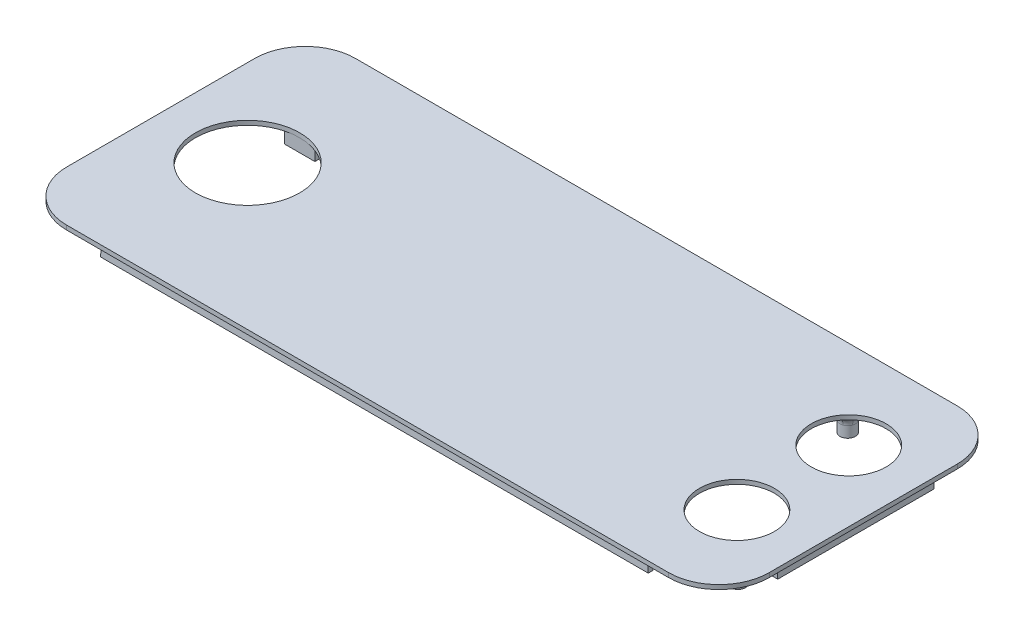
from build123d import *

# Parameters (mm, degrees)
BOSS_EXTRUDE1_DEPTH  = 1
HOLES_R              = 8.625
HOLES_R_2            = 12
CUT_EXTRUDE2_DEPTH   = 1
SKETCH2_W            = 7
SKETCH2_H            = 4.75
BOSS_EXTRUDE2_DEPTH  = 3
SKETCH3_R            = 1
CUT_EXTRUDE3_DEPTH   = 2.5
BOARD_POST_HOLES_R   = 1.75
BOARD_POST_HOLES_R_2 = 1
BOSS_EXTRUDE3_DEPTH  = 5
END_STOPS_W          = 1.8
END_STOPS_H          = 36
BOSS_EXTRUDE4_DEPTH  = 3
SKETCH7_W            = 125.842369002
SKETCH7_H            = 0.8
SKETCH7_W_2          = 127.094788144
BOSS_EXTRUDE5_DEPTH  = 3
BOSS_EXTRUDE5_TAPER  = -3
FILLET1_R            = 2
SKETCH8_R            = 1.75
BOSS_EXTRUDE6_DEPTH  = 5
SKETCH9_R            = 0.55
CUT_EXTRUDE4_DEPTH   = 4
FILLET2_R            = 2.5


with BuildPart() as part:
    # Cover → Boss-Extrude1 (new body)
    with BuildSketch(Plane(origin=(0, 0, 0), x_dir=(1, 0, 0), z_dir=(0, 1, 0))):
        with BuildLine():
            Line((85.9, -21.65), (85.9, 21.65))
            ThreePointArc((85.9, 21.65), (82.502438662, 29.852438662), (74.3, 33.25))
            Line((74.3, 33.25), (-64.3, 33.25))
            ThreePointArc((-64.3, 33.25), (-72.502438662, 29.852438662), (-75.9, 21.65))
            Line((-75.9, 21.65), (-75.9, -21.65))
            ThreePointArc((-75.9, -21.65), (-72.502438662, -29.852438662), (-64.3, -33.25))
            Line((-64.3, -33.25), (74.3, -33.25))
            ThreePointArc((74.3, -33.25), (82.502438662, -29.852438662), (85.9, -21.65))
        make_face()
    extrude(amount=BOSS_EXTRUDE1_DEPTH)

    # Holes → Cut-Extrude2 (cut)
    with BuildSketch(Plane(origin=(0, 0, 0), x_dir=(1, 0, 0), z_dir=(0, 1, 0))):
        with Locations((69.675, 12.875)):
            Circle(HOLES_R)
        with Locations((69.675, -12.875)):
            Circle(HOLES_R)
        with Locations((-55.9, 0)):
            Circle(HOLES_R_2)
    extrude(amount=CUT_EXTRUDE2_DEPTH, mode=Mode.SUBTRACT)

    # Sketch2 → Boss-Extrude2 (add)
    with BuildSketch(Plane(origin=(0, 0, 0), x_dir=(-1, 0, 0), z_dir=(0, -1, 0))):
        with Locations((55.9, -14.375)):
            Rectangle(SKETCH2_W, SKETCH2_H)
        with Locations((55.9, 14.375)):
            Rectangle(SKETCH2_W, SKETCH2_H)
    extrude(amount=BOSS_EXTRUDE2_DEPTH)

    # Sketch3 → Cut-Extrude3 (cut)
    with BuildSketch(Plane(origin=(0, -3, 0), x_dir=(-1, 0, 0), z_dir=(0, -1, 0))):
        with Locations((55.9, -14.375)):
            Circle(SKETCH3_R)
        with Locations((55.9, 14.375)):
            Circle(SKETCH3_R)
    extrude(amount=-CUT_EXTRUDE3_DEPTH, mode=Mode.SUBTRACT)

    # Board Post Holes → Boss-Extrude3 (add)
    with BuildSketch(Plane(origin=(0, 0, 0), x_dir=(-1, 0, 0), z_dir=(0, -1, 0))):
        with Locations((-2.009797874, -0.85)):
            Circle(BOARD_POST_HOLES_R)
        with Locations((-2.009797874, -0.85)):
            Circle(BOARD_POST_HOLES_R_2, mode=Mode.SUBTRACT)
        with Locations((-2.009797874, 13.35)):
            Circle(BOARD_POST_HOLES_R)
        with Locations((-2.009797874, 13.35)):
            Circle(BOARD_POST_HOLES_R_2, mode=Mode.SUBTRACT)
        with Locations((-41.209797874, 13.35)):
            Circle(BOARD_POST_HOLES_R)
        with Locations((-41.209797874, 13.35)):
            Circle(BOARD_POST_HOLES_R_2, mode=Mode.SUBTRACT)
        with Locations((-41.209797874, -0.85)):
            Circle(BOARD_POST_HOLES_R)
        with Locations((-41.209797874, -0.85)):
            Circle(BOARD_POST_HOLES_R_2, mode=Mode.SUBTRACT)
    extrude(amount=BOSS_EXTRUDE3_DEPTH)

    # End Stops → Boss-Extrude4 (add)
    with BuildSketch(Plane.XZ):
        with Locations((-73.3, 0.962548754)):
            Rectangle(END_STOPS_W, END_STOPS_H)
        with Locations((83.3, 0)):
            Rectangle(END_STOPS_W, END_STOPS_H)
    extrude(amount=BOSS_EXTRUDE4_DEPTH)

    # Sketch7 → Boss-Extrude5 (add)
    with BuildSketch(Plane.XZ):
        with Locations((5, 31.15)):
            Rectangle(SKETCH7_W, SKETCH7_H)
        with Locations((5, -31.15)):
            Rectangle(SKETCH7_W_2, SKETCH7_H)
    extrude(amount=BOSS_EXTRUDE5_DEPTH, taper=BOSS_EXTRUDE5_TAPER)

    # Fillet1
    fillet1_edges = [part.edges().sort_by_distance(p)[0] for p in [
        (3.759797874, 0, 0.85),
        (3.759797874, 0, -13.35),
        (42.959797874, 0, -13.35),
        (42.959797874, 0, 0.85),
    ]]
    fillet(fillet1_edges, radius=FILLET1_R)

    # Sketch8 → Boss-Extrude6 (add)
    with BuildSketch(Plane.XZ):
        with Locations((60.92, 21.4)):
            Circle(SKETCH8_R)
        with Locations((78.43, 21.4)):
            Circle(SKETCH8_R)
        with Locations((60.92, -21.4)):
            Circle(SKETCH8_R)
        with Locations((78.43, -21.4)):
            Circle(SKETCH8_R)
    extrude(amount=BOSS_EXTRUDE6_DEPTH)

    # Sketch9 → Cut-Extrude4 (cut)
    with BuildSketch(Plane(origin=(0, -5, 0), x_dir=(-1, 0, 0), z_dir=(0, -1, 0))):
        with Locations((-60.92, -21.4)):
            Circle(SKETCH9_R)
        with Locations((-78.43, -21.4)):
            Circle(SKETCH9_R)
        with Locations((-60.92, 21.4)):
            Circle(SKETCH9_R)
        with Locations((-78.43, 21.4)):
            Circle(SKETCH9_R)
    extrude(amount=-CUT_EXTRUDE4_DEPTH, mode=Mode.SUBTRACT)

    # Fillet2
    fillet2_edges = [part.edges().sort_by_distance(p)[0] for p in [
        (59.17, 0, 21.4),
        (76.68, 0, 21.4),
        (59.17, 0, -21.4),
        (76.68, 0, -21.4),
    ]]
    fillet(fillet2_edges, radius=FILLET2_R)


solid = part.part
